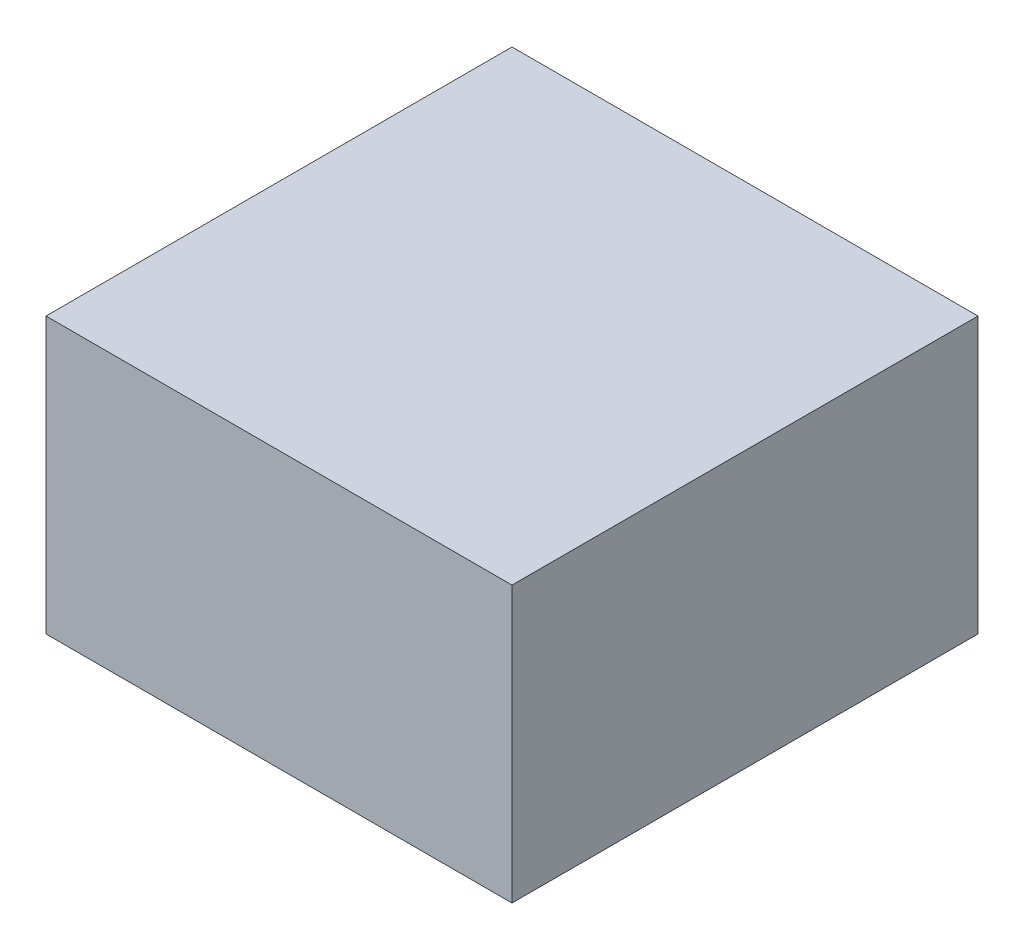
from build123d import *

# Parameters (mm, degrees)
SKETCH1_W           = 110
SKETCH1_H           = 110
BOSS_EXTRUDE1_DEPTH = 65


with BuildPart() as part:
    # Sketch1 → Boss-Extrude1 (new body)
    with BuildSketch(Plane(origin=(0, 0, 0), x_dir=(1, 0, 0), z_dir=(0, 1, 0))):
        Rectangle(SKETCH1_W, SKETCH1_H)
    extrude(amount=BOSS_EXTRUDE1_DEPTH)


solid = part.part
